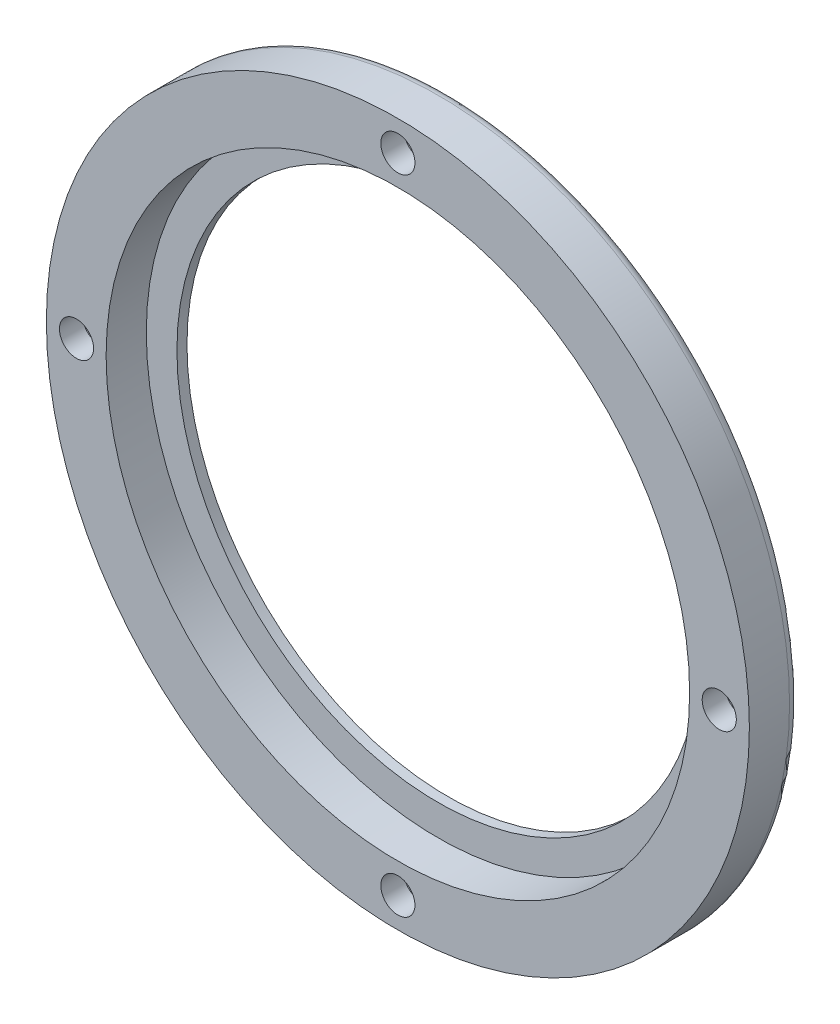
from build123d import *

# Parameters (mm, degrees)
SKETCH_1_W                    = 35
SKETCH_1_H                    = 5
HOLE_WIZARD_3_4_3_4_1_D       = 3.4
HOLE_WIZARD_3_4_3_4_1_DEPTH   = 5
HOLE_WIZARD_M48_1_D           = 52
HOLE_WIZARD_M48_1_DEPTH       = 5
HOLE_WIZARD_M48_1_CBORE_D     = 58.1
HOLE_WIZARD_M48_1_CBORE_DEPTH = 4
FILLET_1_R                    = 1
SKETCH_17_R                   = 2.8
CUT_EXTRUDE_9_DEPTH           = 2.7


with BuildPart() as part:
    # 草图1 → 旋转1 (revolve)
    with BuildSketch(Plane(origin=(0, 0, 0), x_dir=(1, 0, 0), z_dir=(0, 1, 0))):
        with Locations((17.5, 26.5)):
            Rectangle(SKETCH_1_W, SKETCH_1_H)
    revolve(axis=Axis((0, 0, -29), (0, 0, 1)))

    # Ø3.4 (3.4) 直径孔1
    with Locations(Plane(origin=(0, 0, -29), x_dir=(-1, 0, 0), z_dir=(0, 0, -1))):
        with Locations((0, -32), (-32, 0), (0, 32), (32, 0)):
            Hole(HOLE_WIZARD_3_4_3_4_1_D / 2, depth=HOLE_WIZARD_3_4_3_4_1_DEPTH)

    # M48 六角头螺栓的柱形沉头孔1
    with Locations(Plane.XY.offset(-24)):
        with Locations((0, 0)):
            CounterBoreHole(HOLE_WIZARD_M48_1_D / 2, HOLE_WIZARD_M48_1_CBORE_D / 2, HOLE_WIZARD_M48_1_CBORE_DEPTH, depth=HOLE_WIZARD_M48_1_DEPTH)

    # 圆角1
    fillet_1_edges = [part.edges().sort_by_distance(p)[0] for p in [
        (-35, 0, -29),
    ]]
    fillet(fillet_1_edges, radius=FILLET_1_R)

    # 草图17 → 切除-拉伸9 (cut)
    with BuildSketch(Plane(origin=(0, 0, -29), x_dir=(-1, 0, 0), z_dir=(0, 0, -1))):
        with Locations((0, -32)):
            Circle(SKETCH_17_R)
        with Locations((-32, 0)):
            Circle(SKETCH_17_R)
        with Locations((0, 32)):
            Circle(SKETCH_17_R)
        with Locations((32, 0)):
            Circle(SKETCH_17_R)
    extrude(amount=-CUT_EXTRUDE_9_DEPTH, mode=Mode.SUBTRACT)


solid = part.part
